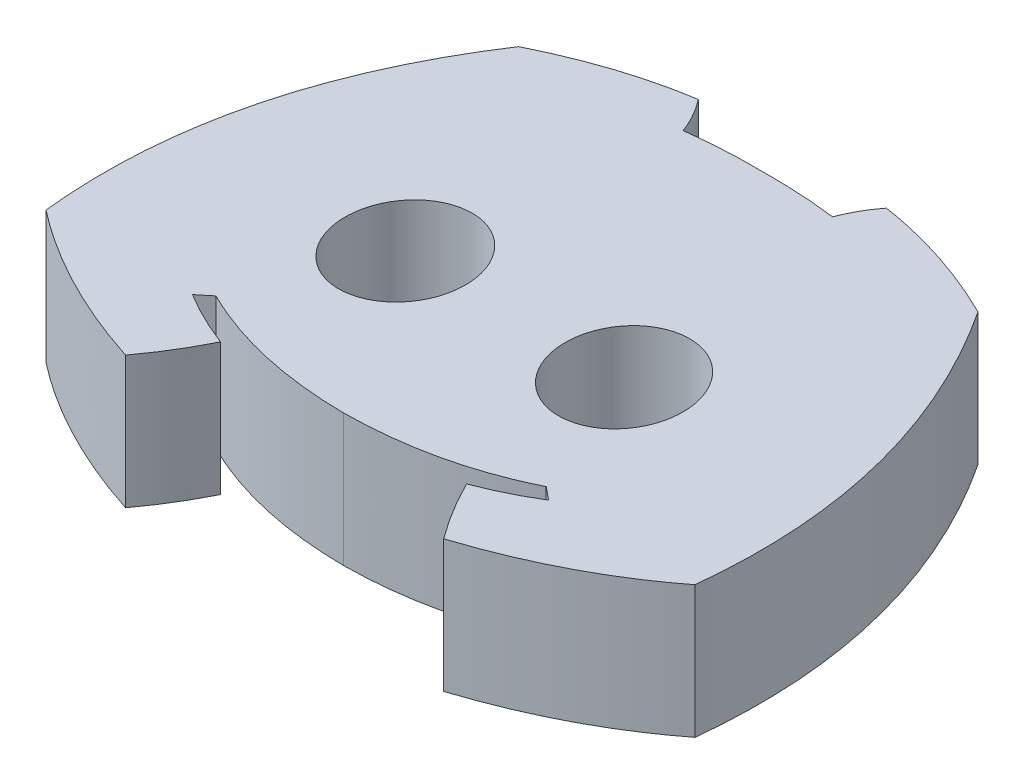
from build123d import *

# Parameters (mm, degrees)
BOSS_EXTRUDE1_DEPTH = 2


with BuildPart() as part:
    # Sketch1 → Boss-Extrude1 (new body)
    with BuildSketch(Plane(origin=(0, 0, 0), x_dir=(1, 0, 0), z_dir=(0, 1, 0))):
        with BuildLine():
            add(Edge.make_bspline(
                [(8.0208395, 2.021879058), (6.63811175, 2.033994704), (5.523272822, 2.589745056)],
                knots=[0.021775029, 0.021775029, 0.021775029, 1, 1, 1], degree=2))
            add(Edge.make_bspline(
                [(8.0208395, 2.021879058), (9.40356725, 2.033994704), (10.518406178, 2.589745056)],
                knots=[0.021775029, 0.021775029, 0.021775029, 1, 1, 1], degree=2))
            add(Edge.make_bspline(
                [(10.518406178, 2.589745056), (10.714311063, 2.429756066)],
                knots=[0, 0, 1, 1], degree=1))
            add(Edge.make_bspline(
                [(10.714311063, 2.429756066), (10.330675492, 2.193044756), (9.881715299, 2.021609044)],
                knots=[0, 0, 0, 1, 1, 1], degree=2))
            add(Edge.make_bspline(
                [(9.881715299, 2.021609044), (10.122513652, 1.540027142), (10.426983898, 1.130253657)],
                knots=[0, 0, 0, 1, 1, 1], degree=2))
            add(Edge.make_bspline(
                [(10.426983898, 1.130253657), (11.859617556, 1.595829961), (12.929624995, 2.429756066)],
                knots=[0, 0, 0, 1, 1, 1], degree=2))
            add(Edge.make_bspline(
                [(12.929624995, 2.429756066), (13.251202925, 5.47692729), (11.495268034, 8.144053116)],
                knots=[0, 0, 0, 1, 1, 1], degree=2))
            add(Edge.make_bspline(
                [(11.495268034, 8.144053116), (10.459789253, 8.656956809), (9.443133293, 8.809542072)],
                knots=[0, 0, 0, 1, 1, 1], degree=2))
            add(Edge.make_bspline(
                [(9.443133293, 8.809542072), (9.2579039, 8.575568103), (9.151516486, 8.288797774)],
                knots=[0, 0, 0, 1, 1, 1], degree=2))
            add(Edge.make_bspline(
                [(9.151516486, 8.288797774), (8.586971906, 8.360115377), (8.0208395, 8.35128709)],
                knots=[0, 0, 0, 1, 1, 1], degree=2))
            add(Edge.make_bspline(
                [(6.890162514, 8.288797774), (7.454707093, 8.360115377), (8.0208395, 8.35128709)],
                knots=[0, 0, 0, 1, 1, 1], degree=2))
            add(Edge.make_bspline(
                [(6.598545707, 8.809542072), (6.783775099, 8.575568103), (6.890162514, 8.288797774)],
                knots=[0, 0, 0, 1, 1, 1], degree=2))
            add(Edge.make_bspline(
                [(4.546410966, 8.144053116), (5.581889746, 8.656956809), (6.598545707, 8.809542072)],
                knots=[0, 0, 0, 1, 1, 1], degree=2))
            add(Edge.make_bspline(
                [(3.112054004, 2.429756066), (2.790476075, 5.47692729), (4.546410966, 8.144053116)],
                knots=[0, 0, 0, 1, 1, 1], degree=2))
            add(Edge.make_bspline(
                [(5.614695102, 1.130253657), (4.182061443, 1.595829961), (3.112054004, 2.429756066)],
                knots=[0, 0, 0, 1, 1, 1], degree=2))
            add(Edge.make_bspline(
                [(6.1599637, 2.021609044), (5.919165348, 1.540027142), (5.614695102, 1.130253657)],
                knots=[0, 0, 0, 1, 1, 1], degree=2))
            add(Edge.make_bspline(
                [(5.327367936, 2.429756066), (5.711003508, 2.193044756), (6.1599637, 2.021609044)],
                knots=[0, 0, 0, 1, 1, 1], degree=2))
            add(Edge.make_bspline(
                [(5.523272822, 2.589745056), (5.327367936, 2.429756066)],
                knots=[0, 0, 1, 1], degree=1))
        make_face()
        with BuildLine():
            add(Edge.make_bspline(
                [(6.412152968, 5.611158251), (4.854261906, 5.682265312), (5.564693339, 4.145630181), (6.275124772, 2.60899505), (7.122584402, 4.07452312), (7.970044031, 5.54005119), (6.412152968, 5.611158251)],
                knots=[0, 0, 0, 2.094395102, 2.094395102, 4.188790205, 4.188790205, 6.283185307, 6.283185307, 6.283185307], degree=2, weights=[1, 0.5, 1, 0.5, 1, 0.5, 1]))
        make_face(mode=Mode.SUBTRACT)
        with BuildLine():
            add(Edge.make_bspline(
                [(9.629526031, 5.611158251), (8.071634969, 5.54005119), (8.919094598, 4.07452312), (9.766554227, 2.60899505), (10.47698566, 4.145630181), (11.187417093, 5.682265312), (9.629526031, 5.611158251)],
                knots=[0, 0, 0, 2.094395102, 2.094395102, 4.188790205, 4.188790205, 6.283185307, 6.283185307, 6.283185307], degree=2, weights=[1, 0.5, 1, 0.5, 1, 0.5, 1]))
        make_face(mode=Mode.SUBTRACT)
    extrude(amount=BOSS_EXTRUDE1_DEPTH)


solid = part.part
